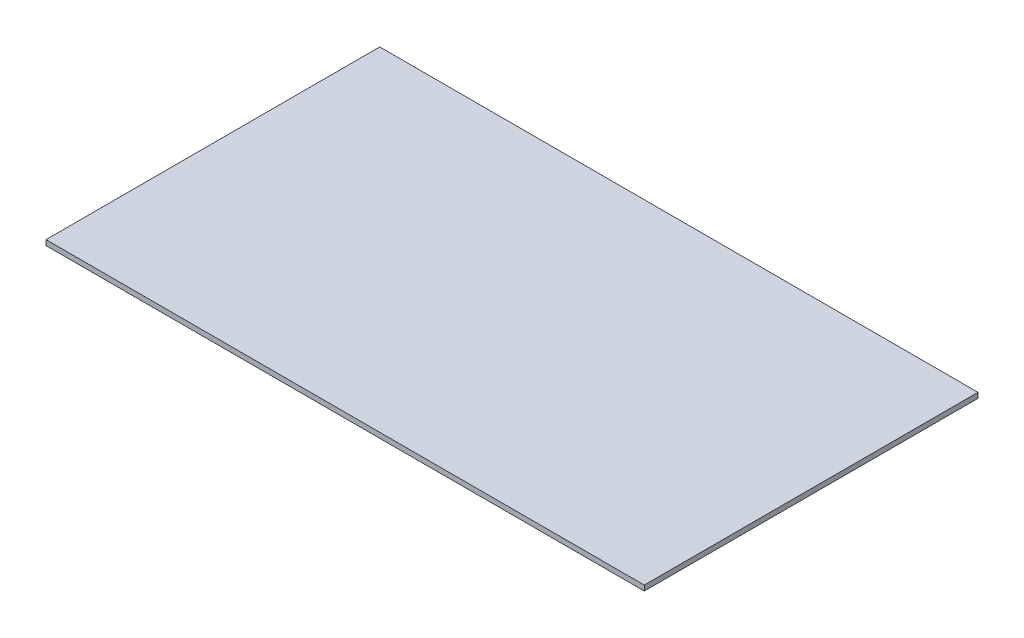
from build123d import *

# Parameters (mm, degrees)
SKETCH1_W           = 2185.74
SKETCH1_H           = 1219.2
BOSS_EXTRUDE1_DEPTH = 19.05


with BuildPart() as part:
    # Sketch1 → Boss-Extrude1 (new body)
    with BuildSketch(Plane(origin=(0, 0, 0), x_dir=(1, 0, 0), z_dir=(0, 1, 0))):
        Rectangle(SKETCH1_W, SKETCH1_H)
    extrude(amount=BOSS_EXTRUDE1_DEPTH)


solid = part.part
